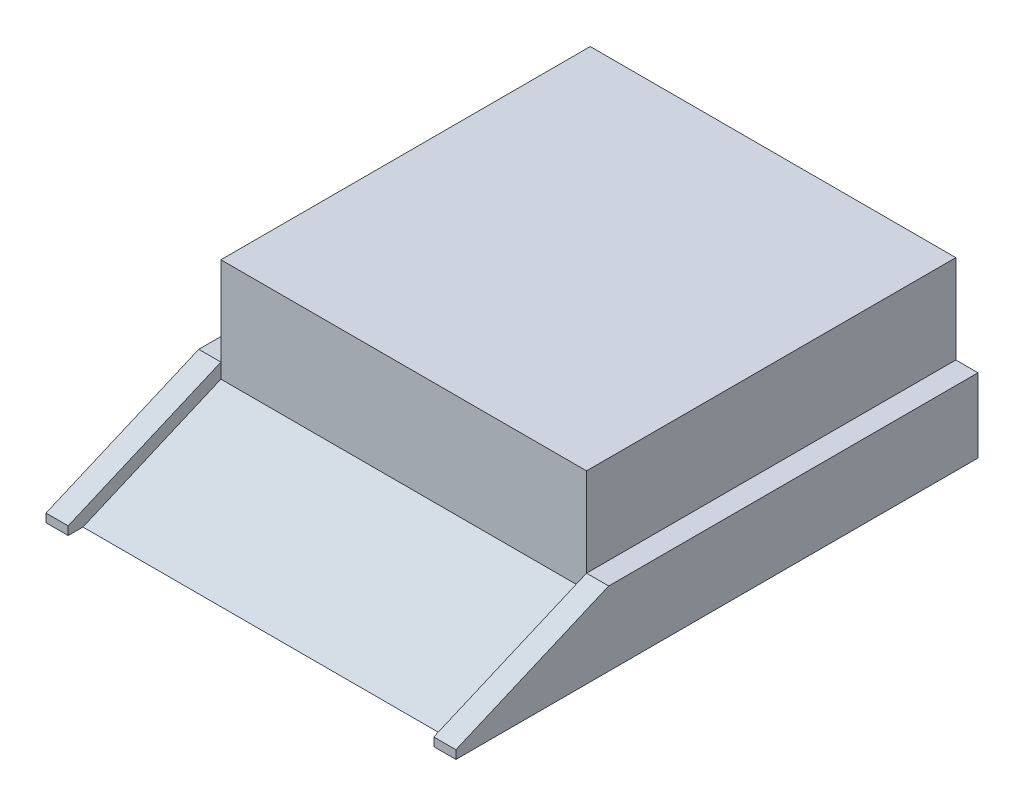
from build123d import *

# Parameters (mm, degrees)
SKETCH_1_W          = 2775
SKETCH_1_H          = 3534
EXTRUDE_1_DEPTH     = 500
CUT_EXTRUDE_1_DEPTH = 3328.598833994
CUT_EXTRUDE_START   = -150
SKETCH_2_3_W        = 2500
SKETCH_2_3_H        = 100
CUT_EXTRUDE_2_DEPTH = 2475
EXTRUDE_START       = -400
SKETCH_3_W          = 2475
SKETCH_3_H          = 2500
EXTRUDE_2_DEPTH     = 1100


with BuildPart() as part:
    # 草图1 → 凸台-拉伸1 (new body)
    with BuildSketch(Plane(origin=(0, 0, 0), x_dir=(1, 0, 0), z_dir=(0, 1, 0))):
        Rectangle(SKETCH_1_W, SKETCH_1_H)
    extrude(amount=EXTRUDE_1_DEPTH)

    # 草图2 → 切除-拉伸1 (cut, through all)
    with BuildSketch(Plane(origin=(1387.5, 0, 0), x_dir=(0, 0, -1), z_dir=(1, 0, 0))):
        Polygon((-1767, 57.173447537), (-733, 500), (-1767, 500), align=None)
    extrude(amount=-CUT_EXTRUDE_1_DEPTH, mode=Mode.SUBTRACT)

    # 草图2<3> → 切除-拉伸2 (cut)
    with BuildSketch(Plane(origin=(1387.5, 0, 0), x_dir=(0, 0, -1), z_dir=(1, 0, 0)).offset(CUT_EXTRUDE_START)):
        Polygon((-1667, 0), (-733, 400), (-733, 500), (-1767, 57.173447537), (-1767, 0), align=None)
        with Locations((517, 450)):
            Rectangle(SKETCH_2_3_W, SKETCH_2_3_H)
    extrude(amount=-CUT_EXTRUDE_2_DEPTH, mode=Mode.SUBTRACT)

    # 草图3 → 凸台-拉伸2 (add)
    with BuildSketch(Plane(origin=(0, 400, 0), x_dir=(1, 0, 0), z_dir=(0, 1, 0)).offset(EXTRUDE_START)):
        with Locations((0, 517)):
            Rectangle(SKETCH_3_W, SKETCH_3_H)
    extrude(amount=EXTRUDE_2_DEPTH)


solid = part.part
